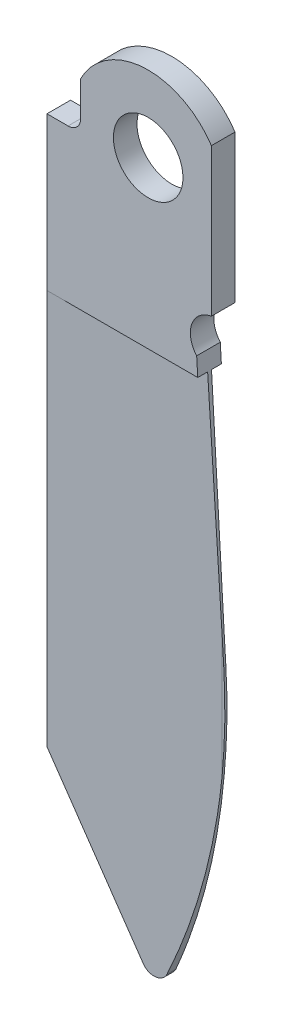
from build123d import *

# Parameters (mm, degrees)
BOSS_EXTRUDE1_DEPTH = 0.7112
SKETCH2_R           = 2.0955
CUT_EXTRUDE1_DEPTH  = 2.4224
CUT_EXTRUDE2_DEPTH  = 49.6824
SKETCH4_W           = 0.6477
SKETCH4_H           = 7.286325031
CUT_EXTRUDE4_DEPTH  = 25.4


with BuildPart() as part:
    # Sketch1 → Boss-Extrude1 (new body, symmetric)
    with BuildSketch(Plane.XY):
        with BuildLine():
            Line((54.87519109, 58.900672801), (54.87519109, 25.880672801))
            Line((54.87519109, 25.880672801), (60.323650659, 17.097007032))
            ThreePointArc((60.323650659, 17.097007032), (61.02184914, 16.738358549), (61.666295368, 17.186464467))
            ThreePointArc((61.666295368, 17.186464467), (64.337974251, 25.783780398), (64.874140477, 34.770672801))
            Line((64.874140477, 34.770672801), (63.892088906, 50.780757429))
            ThreePointArc((63.892088906, 50.780757429), (63.598614861, 52.297421008), (64.78119109, 53.291357066))
            Line((64.78119109, 53.291357066), (64.78119109, 62.189940891))
            ThreePointArc((64.78119109, 62.189940891), (60.720306841, 64.227784091), (56.90719109, 61.757210459))
            Line((56.90719109, 61.757210459), (56.90719109, 59.662672801))
            ThreePointArc((56.90719109, 59.662672801), (56.684006458, 59.123857434), (56.14519109, 58.900672801))
            Line((56.14519109, 58.900672801), (54.87519109, 58.900672801))
        make_face()
    extrude(amount=BOSS_EXTRUDE1_DEPTH, both=True)

    # Sketch2 → Cut-Extrude1 (cut, through all)
    with BuildSketch(Plane.XY.offset(0.7112)):
        with Locations((60.97119109, 59.662672801)):
            Circle(SKETCH2_R)
    extrude(amount=-CUT_EXTRUDE1_DEPTH, mode=Mode.SUBTRACT)

    # Sketch3 → Cut-Extrude2 (cut)
    with BuildSketch(Plane(origin=(0, 0, 0), x_dir=(1, 0, 0), z_dir=(0, 1, 0))):
        Polygon((64.78119109, 0.0635), (54.87519109, 0.7112), (64.78119109, 0.7112), align=None)
        Polygon((54.87519109, -0.7112), (64.78119109, -0.0635), (64.78119109, -0.7112), align=None)
    extrude(amount=CUT_EXTRUDE2_DEPTH, mode=Mode.SUBTRACT)

    # Sketch4 → Cut-Extrude4 (cut)
    with BuildSketch(Plane.ZY.offset(-64.78119109)):
        with Locations((0.38735, 32.642835537)):
            Rectangle(SKETCH4_W, SKETCH4_H)
        with Locations((-0.38735, 32.642835537)):
            Rectangle(SKETCH4_W, SKETCH4_H)
    extrude(amount=-CUT_EXTRUDE4_DEPTH, mode=Mode.SUBTRACT)


solid = part.part
